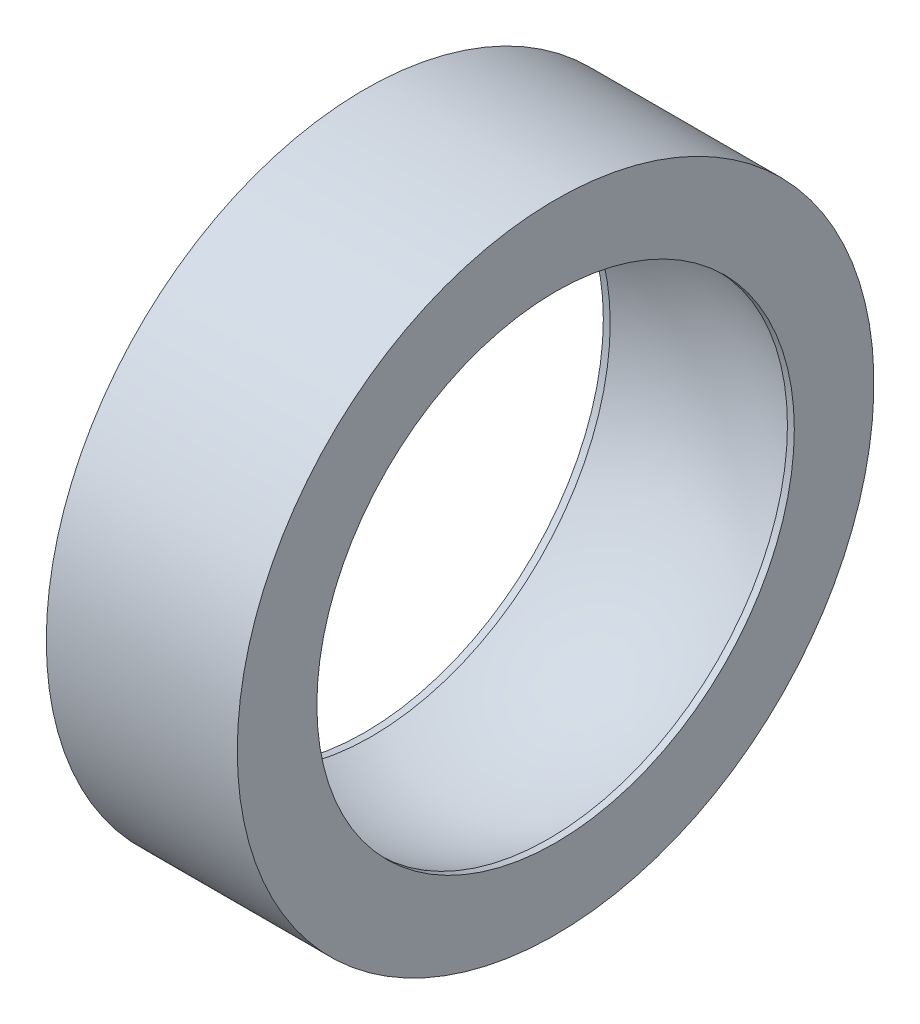
from build123d import *


with BuildPart() as part:
    # Sketch1 → Revolve1 (revolve)
    with BuildSketch(Plane.XY):
        with BuildLine():
            Line((3.048, 10.16), (-3.048, 10.16))
            Line((-3.048, 10.16), (-3.048, 7.62))
            Line((-3.048, 7.62), (-2.828424296, 7.62))
            ThreePointArc((-2.828424296, 7.62), (0, 8.128), (2.828424296, 7.62))
            Line((2.828424296, 7.62), (3.048, 7.62))
            Line((3.048, 7.62), (3.048, 10.16))
        make_face()
    revolve(axis=Axis((-10.16, 0, 0), (1, 0, 0)))


solid = part.part
